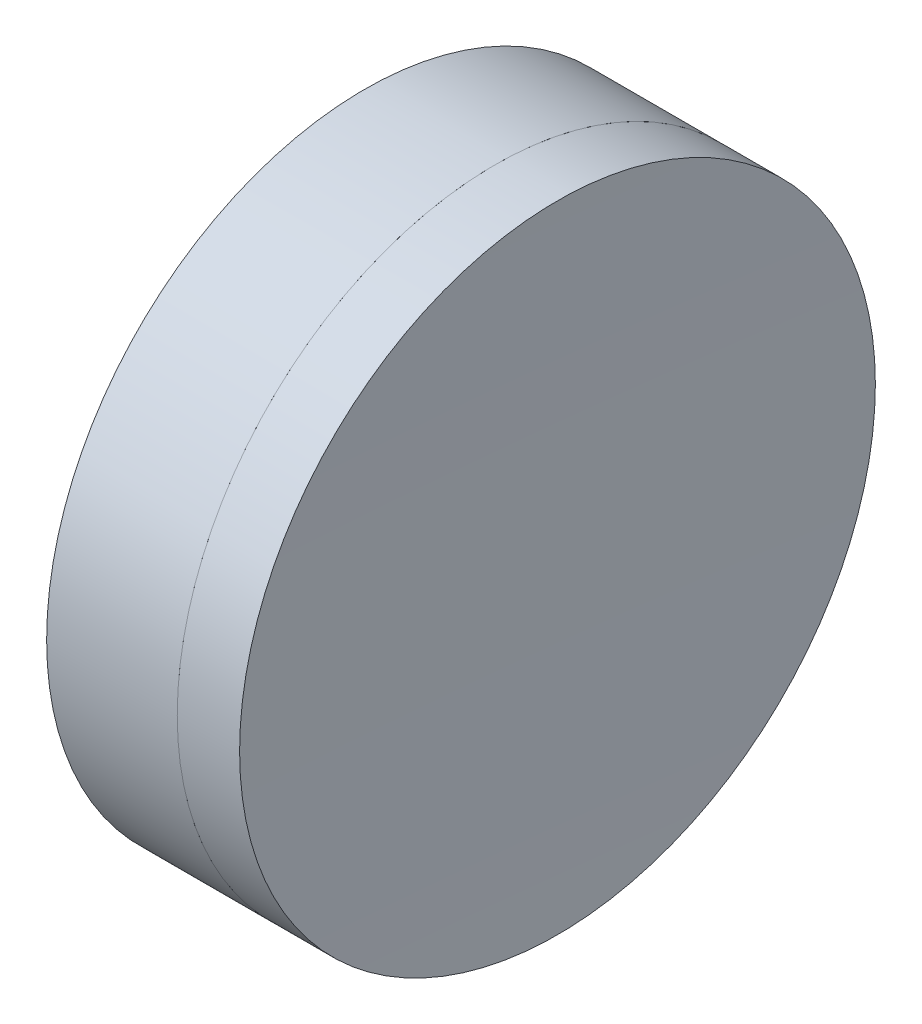
from build123d import *


with BuildPart() as part:
    # 草图1 one side → 旋转1 (revolve)
    with BuildSketch(Plane(origin=(0, 0, 0), x_dir=(1, 0, 0), z_dir=(0, 1, 0)), mode=Mode.PRIVATE) as revolve_1_sk:
        with BuildLine():
            Line((257.337837551, 12.7), (252.119941814, 12.7))
            ThreePointArc((252.119941814, 12.7), (253.299471761, 6.398626954), (253.694650541, 0))
            Line((253.694650541, 0), (255.694650541, 0))
            ThreePointArc((255.694650541, 0), (256.10715228, 6.402930258), (257.337837551, 12.7))
        make_face()
    revolve(revolve_1_sk.sketch.rotate(Axis((-0.816062176, 0, 0), (1, 0, 0)), 180), axis=Axis((-0.816062176, 0, 0), (1, 0, 0)))  # turned: the seam where the file's is


with BuildPart() as body_2:
    # 草图2 one side → 旋转3 (revolve)
    with BuildSketch(Plane(origin=(0, 0, 0), x_dir=(1, 0, 0), z_dir=(0, 1, 0)), mode=Mode.PRIVATE) as revolve_3_sk:
        with BuildLine():
            Line((259.829073932, 12.7), (257.337837551, 12.7))
            ThreePointArc((257.337837551, 12.7), (256.10715228, 6.402930258), (255.694650541, 0))
            Line((255.694650541, 0), (259.694650541, 0))
            ThreePointArc((259.694650541, 0), (259.72825733, 6.350355692), (259.829073932, 12.7))
        make_face()
    revolve(revolve_3_sk.sketch.rotate(Axis((252.119941814, 0, 0), (1, 0, 0)), 180), axis=Axis((252.119941814, 0, 0), (1, 0, 0)))  # turned: the seam where the file's is


solid = Compound([part.part, body_2.part])
